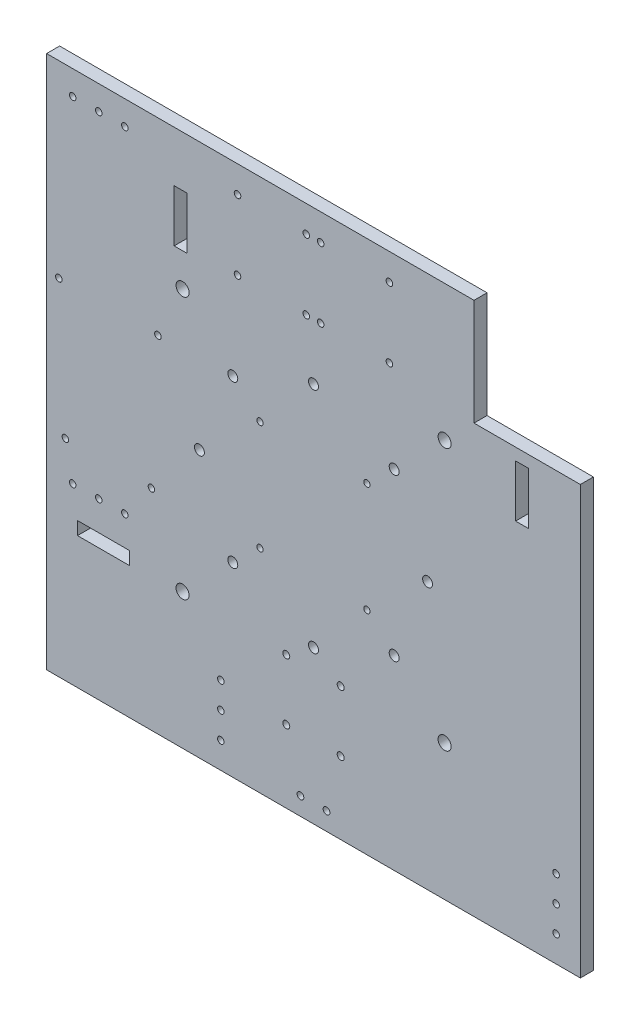
from build123d import *

# Parameters (mm, degrees)
SKETCH1_W           = 260
SKETCH1_H           = 260
SKETCH1_R           = 1.55
SKETCH1_R_2         = 1.5875
SKETCH1_R_3         = 1.6
SKETCH1_R_4         = 1.7
SKETCH1_R_5         = 2.415
SKETCH1_R_6         = 1.651
BOSS_EXTRUDE2_DEPTH = 6.35
SKETCH5_W           = 52.8
SKETCH5_H           = 52.8
CUT_EXTRUDE1_DEPTH  = 7.35
SKETCH6_R           = 3.175
CUT_EXTRUDE2_DEPTH  = 7.35
SKETCH7_R           = 1.5875
CUT_EXTRUDE3_DEPTH  = 7.35
SKETCH8_W           = 25.4
SKETCH8_H           = 6.35
SKETCH8_W_2         = 6.35
SKETCH8_H_2         = 25.4
CUT_EXTRUDE4_DEPTH  = 7.35


with BuildPart() as part:
    # Sketch1 → Boss-Extrude2 (new body)
    with BuildSketch(Plane.XY):
        Rectangle(SKETCH1_W, SKETCH1_H)
        with Locations((-26.035, 26.67)):
            Circle(SKETCH1_R, mode=Mode.SUBTRACT)
        with Locations((-26.035, -26.67)):
            Circle(SKETCH1_R, mode=Mode.SUBTRACT)
        with Locations((26.035, 26.67)):
            Circle(SKETCH1_R, mode=Mode.SUBTRACT)
        with Locations((26.035, -26.67)):
            Circle(SKETCH1_R, mode=Mode.SUBTRACT)
        with Locations((-124.036081104, 38.237690774)):
            Circle(SKETCH1_R_2, mode=Mode.SUBTRACT)
        with Locations((-120.861081104, -27.800206824)):
            Circle(SKETCH1_R_2, mode=Mode.SUBTRACT)
        with Locations((-75.776081104, 38.239793176)):
            Circle(SKETCH1_R_2, mode=Mode.SUBTRACT)
        with Locations((-37, 117)):
            Circle(SKETCH1_R_3, mode=Mode.SUBTRACT)
        with Locations((-37, 83)):
            Circle(SKETCH1_R_3, mode=Mode.SUBTRACT)
        with Locations((-3.5, 117)):
            Circle(SKETCH1_R_3, mode=Mode.SUBTRACT)
        with Locations((-3.5, 83)):
            Circle(SKETCH1_R_3, mode=Mode.SUBTRACT)
        with Locations((3.5, 117)):
            Circle(SKETCH1_R_3, mode=Mode.SUBTRACT)
        with Locations((37, 117)):
            Circle(SKETCH1_R_3, mode=Mode.SUBTRACT)
        with Locations((37, 83)):
            Circle(SKETCH1_R_3, mode=Mode.SUBTRACT)
        with Locations((3.5, 83)):
            Circle(SKETCH1_R_3, mode=Mode.SUBTRACT)
        with Locations((-13.25, -65.25)):
            Circle(SKETCH1_R_4, mode=Mode.SUBTRACT)
        with Locations((13.25, -65.25)):
            Circle(SKETCH1_R_4, mode=Mode.SUBTRACT)
        with Locations((13.25, -94.75)):
            Circle(SKETCH1_R_4, mode=Mode.SUBTRACT)
        with Locations((-13.25, -94.75)):
            Circle(SKETCH1_R_4, mode=Mode.SUBTRACT)
        with Locations((0, 55.575)):
            Circle(SKETCH1_R_5, mode=Mode.SUBTRACT)
        with Locations((-55.575, 0)):
            Circle(SKETCH1_R_5, mode=Mode.SUBTRACT)
        with Locations((0, -55.575)):
            Circle(SKETCH1_R_5, mode=Mode.SUBTRACT)
        with Locations((55.575, 0)):
            Circle(SKETCH1_R_5, mode=Mode.SUBTRACT)
        with Locations((-39.297459364, 39.297459364)):
            Circle(SKETCH1_R_5, mode=Mode.SUBTRACT)
        with Locations((39.297459364, 39.297459364)):
            Circle(SKETCH1_R_5, mode=Mode.SUBTRACT)
        with Locations((39.297459364, -39.297459364)):
            Circle(SKETCH1_R_5, mode=Mode.SUBTRACT)
        with Locations((-39.297459364, -39.297459364)):
            Circle(SKETCH1_R_5, mode=Mode.SUBTRACT)
        with Locations((-78.951081104, -27.800206824)):
            Circle(SKETCH1_R_2, mode=Mode.SUBTRACT)
        with Locations((6.35, -121.3)):
            Circle(SKETCH1_R_6, mode=Mode.SUBTRACT)
        with Locations((-6.35, -121.3)):
            Circle(SKETCH1_R_6, mode=Mode.SUBTRACT)
        with Locations((121.3, 126.35)):
            Circle(SKETCH1_R_6, mode=Mode.SUBTRACT)
        with Locations((121.3, 113.65)):
            Circle(SKETCH1_R_6, mode=Mode.SUBTRACT)
    extrude(amount=BOSS_EXTRUDE2_DEPTH)

    # Sketch5 → Cut-Extrude1 (cut, through all)
    with BuildSketch(Plane(origin=(0, 0, 0), x_dir=(-1, 0, 0), z_dir=(0, 0, -1))):
        with Locations((-104.6, 104.6)):
            Rectangle(SKETCH5_W, SKETCH5_H)
    extrude(amount=-CUT_EXTRUDE1_DEPTH, mode=Mode.SUBTRACT)

    # Sketch6 → Cut-Extrude2 (cut, through all)
    with BuildSketch(Plane(origin=(0, 0, 0), x_dir=(-1, 0, 0), z_dir=(0, 0, -1))):
        with Locations((63.77864005, 63.77864005)):
            Circle(SKETCH6_R)
        with Locations((-63.87464005, 63.77864005)):
            Circle(SKETCH6_R)
        with Locations((-63.87464005, -63.87464005)):
            Circle(SKETCH6_R)
        with Locations((63.77864005, -63.87464005)):
            Circle(SKETCH6_R)
    extrude(amount=-CUT_EXTRUDE2_DEPTH, mode=Mode.SUBTRACT)

    # Sketch7 → Cut-Extrude3 (cut, through all)
    with BuildSketch(Plane(origin=(0, 0, 0), x_dir=(-1, 0, 0), z_dir=(0, 0, -1))):
        with Locations((91.9, 118.189)):
            Circle(SKETCH7_R)
        with Locations((104.6, 118.189)):
            Circle(SKETCH7_R)
        with Locations((117.3, 118.189)):
            Circle(SKETCH7_R)
        with Locations((91.9, -45.133)):
            Circle(SKETCH7_R)
        with Locations((104.6, -45.133)):
            Circle(SKETCH7_R)
        with Locations((117.3, -45.133)):
            Circle(SKETCH7_R)
        with Locations((45.133, -117.3)):
            Circle(SKETCH7_R)
        with Locations((45.133, -104.6)):
            Circle(SKETCH7_R)
        with Locations((45.133, -91.9)):
            Circle(SKETCH7_R)
        with Locations((-118.189, -117.3)):
            Circle(SKETCH7_R)
        with Locations((-118.189, -104.6)):
            Circle(SKETCH7_R)
        with Locations((-118.189, -91.9)):
            Circle(SKETCH7_R)
    extrude(amount=-CUT_EXTRUDE3_DEPTH, mode=Mode.SUBTRACT)

    # Sketch8 → Cut-Extrude4 (cut, through all)
    with BuildSketch(Plane.XY.offset(6.35)):
        with Locations((-102.241050682, -62.663768992)):
            Rectangle(SKETCH8_W, SKETCH8_H)
        with Locations((-64.693745391, 92.61029866)):
            Rectangle(SKETCH8_W_2, SKETCH8_H_2)
        with Locations((101.629283102, 59.681030297)):
            Rectangle(SKETCH8_W_2, SKETCH8_H_2)
    extrude(amount=-CUT_EXTRUDE4_DEPTH, mode=Mode.SUBTRACT)


solid = part.part
